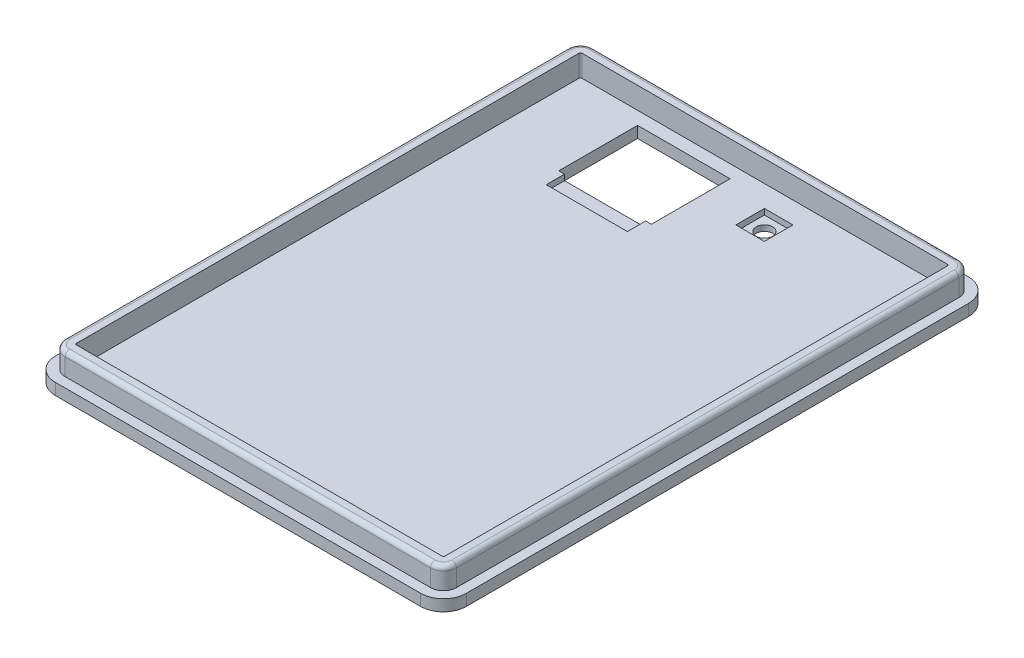
from build123d import *

# Parameters (mm, degrees)
SKETCH1_W           = 180
SKETCH1_H           = 240
BOSS_EXTRUDE1_DEPTH = 5
SKETCH2_R           = 3.6
SKETCH2_W           = 40.55
SKETCH2_H           = 34.5
CUT_EXTRUDE1_DEPTH  = 6
SKETCH3_W           = 12.5
SKETCH3_H           = 12.5
CUT_EXTRUDE2_DEPTH  = 2.5
SKETCH4_W           = 35.55
SKETCH4_H           = 8
CUT_EXTRUDE3_DEPTH  = 2.5
FILLET1_R           = 10
BOSS_EXTRUDE2_DEPTH = 9.5
FILLET2_R           = 2


with BuildPart() as part:
    # Sketch1 → Boss-Extrude1 (new body)
    with BuildSketch(Plane(origin=(0, 0, 0), x_dir=(1, 0, 0), z_dir=(0, 1, 0))):
        with Locations((90, 120)):
            Rectangle(SKETCH1_W, SKETCH1_H)
    extrude(amount=BOSS_EXTRUDE1_DEPTH)

    # Sketch2 → Cut-Extrude1 (cut, through all)
    with BuildSketch(Plane.XZ):
        with Locations((105.55, -215)):
            Circle(SKETCH2_R)
        with Locations((60.275, -207.75)):
            Rectangle(SKETCH2_W, SKETCH2_H)
    extrude(amount=-CUT_EXTRUDE1_DEPTH, mode=Mode.SUBTRACT)

    # Sketch3 → Cut-Extrude2 (cut)
    with BuildSketch(Plane(origin=(0, 5, 0), x_dir=(1, 0, 0), z_dir=(0, 1, 0))):
        with Locations((105.55, 215)):
            Rectangle(SKETCH3_W, SKETCH3_H)
    extrude(amount=-CUT_EXTRUDE2_DEPTH, mode=Mode.SUBTRACT)

    # Sketch4 → Cut-Extrude3 (cut)
    with BuildSketch(Plane(origin=(0, 5, 0), x_dir=(1, 0, 0), z_dir=(0, 1, 0))):
        with Locations((60.275, 186.5)):
            Rectangle(SKETCH4_W, SKETCH4_H)
    extrude(amount=-CUT_EXTRUDE3_DEPTH, mode=Mode.SUBTRACT)

    # Fillet1
    fillet1_edges = [part.edges().sort_by_distance(p)[0] for p in [
        (0, 2.5, -240),
        (180, 2.5, -240),
        (180, 2.5, 0),
        (0, 2.5, 0),
    ]]
    fillet(fillet1_edges, radius=FILLET1_R)

    # Sketch6 → Boss-Extrude2 (add)
    with BuildSketch(Plane(origin=(0, 5, 0), x_dir=(1, 0, 0), z_dir=(0, 1, 0))):
        with BuildLine():
            Line((175.7, 10), (175.7, 230))
            ThreePointArc((175.7, 230), (174.030508653, 234.030508653), (170, 235.7))
            Line((170, 235.7), (10, 235.7))
            ThreePointArc((10, 235.7), (5.969491347, 234.030508653), (4.3, 230))
            Line((4.3, 230), (4.3, 10))
            ThreePointArc((4.3, 10), (5.969491347, 5.969491347), (10, 4.3))
            Line((10, 4.3), (170, 4.3))
            ThreePointArc((170, 4.3), (174.030508653, 5.969491347), (175.7, 10))
        make_face()
        with BuildLine():
            Line((170.7, 10), (170.7, 230))
            ThreePointArc((170.7, 230), (170.494974747, 230.494974747), (170, 230.7))
            Line((170, 230.7), (10, 230.7))
            ThreePointArc((10, 230.7), (9.505025253, 230.494974747), (9.3, 230))
            Line((9.3, 230), (9.3, 10))
            ThreePointArc((9.3, 10), (9.505025253, 9.505025253), (10, 9.3))
            Line((10, 9.3), (170, 9.3))
            ThreePointArc((170, 9.3), (170.494974747, 9.505025253), (170.7, 10))
        make_face(mode=Mode.SUBTRACT)
    extrude(amount=BOSS_EXTRUDE2_DEPTH)

    # Fillet2
    fillet2_edges = [part.edges().sort_by_distance(p)[0] for p in [
        (174.030508653, 14.5, -5.969491347),
        (175.7, 14.5, -120),
        (174.030508653, 14.5, -234.030508653),
        (90, 14.5, -235.7),
        (5.969491347, 14.5, -234.030508653),
        (4.3, 14.5, -120),
        (5.969491347, 14.5, -5.969491347),
        (90, 14.5, -4.3),
    ]]
    fillet(fillet2_edges, radius=FILLET2_R)


solid = part.part
